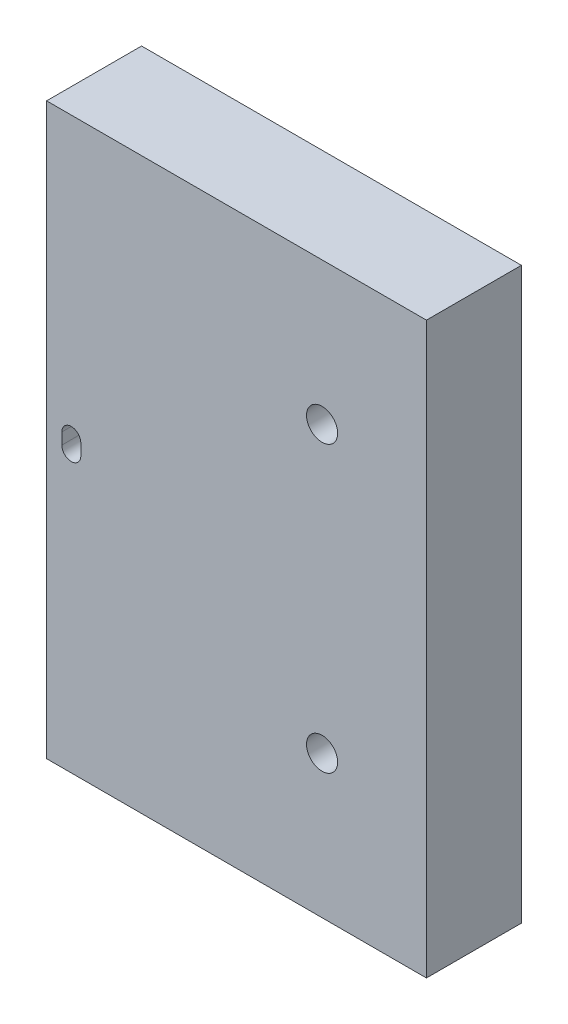
from build123d import *

# Parameters (mm, degrees)
SKETCH1_W                     = 25.4
SKETCH1_H                     = 38.1
BOSS_EXTRUDE1_DEPTH           = 6.35
TAP_DRILL_FOR_3_56_TAP1_D     = 2.0828
TAP_DRILL_FOR_3_56_TAP1_DEPTH = 7.62
TAP_DRILL_FOR_3_56_TAP1_TIP   = 0.625736249
CUT_EXTRUDE1_DEPTH            = 7.35
TAP_DRILL_FOR_3_56_TAP2_D     = 2.0828
TAP_DRILL_FOR_3_56_TAP2_DEPTH = 7.62
TAP_DRILL_FOR_3_56_TAP2_TIP   = 0.625736249


with BuildPart() as part:
    # Sketch1 → Boss-Extrude1 (new body)
    with BuildSketch(Plane.XY):
        Rectangle(SKETCH1_W, SKETCH1_H)
    extrude(amount=BOSS_EXTRUDE1_DEPTH)

    # Tap Drill for #3-56 Tap1
    with Locations(Plane.ZY.offset(12.7)):
        with Locations((2.850000016, 7.224999934), (2.84999953, -11.775000065)):
            Hole(TAP_DRILL_FOR_3_56_TAP1_D / 2, depth=TAP_DRILL_FOR_3_56_TAP1_DEPTH)
            with Locations((0, 0, -(TAP_DRILL_FOR_3_56_TAP1_DEPTH + TAP_DRILL_FOR_3_56_TAP1_TIP / 2))):  # 118° drill point
                Cone(0, TAP_DRILL_FOR_3_56_TAP1_D / 2, TAP_DRILL_FOR_3_56_TAP1_TIP, mode=Mode.SUBTRACT)

    # Sketch4 → Cut-Extrude1 (cut, through all)
    with BuildSketch(Plane.XY.offset(6.35)):
        with BuildLine():
            Line((-10.414, -0.381), (-10.414, 0.381))
            ThreePointArc((-10.414, 0.381), (-11.049, 1.016), (-11.684, 0.381))
            Line((-11.684, 0.381), (-11.684, -0.381))
            ThreePointArc((-11.684, -0.381), (-11.049, -1.016), (-10.414, -0.381))
        make_face()
    extrude(amount=-CUT_EXTRUDE1_DEPTH, mode=Mode.SUBTRACT)

    # Tap Drill for #3-56 Tap2
    with Locations(Plane(origin=(0, 0, 0), x_dir=(1, 0, 0), z_dir=(0, 0, -1))):
        with Locations((5.721, -9.525), (5.721, 9.525)):
            Hole(TAP_DRILL_FOR_3_56_TAP2_D / 2, depth=TAP_DRILL_FOR_3_56_TAP2_DEPTH)
            with Locations((0, 0, -(TAP_DRILL_FOR_3_56_TAP2_DEPTH + TAP_DRILL_FOR_3_56_TAP2_TIP / 2))):  # 118° drill point
                Cone(0, TAP_DRILL_FOR_3_56_TAP2_D / 2, TAP_DRILL_FOR_3_56_TAP2_TIP, mode=Mode.SUBTRACT)


solid = part.part
